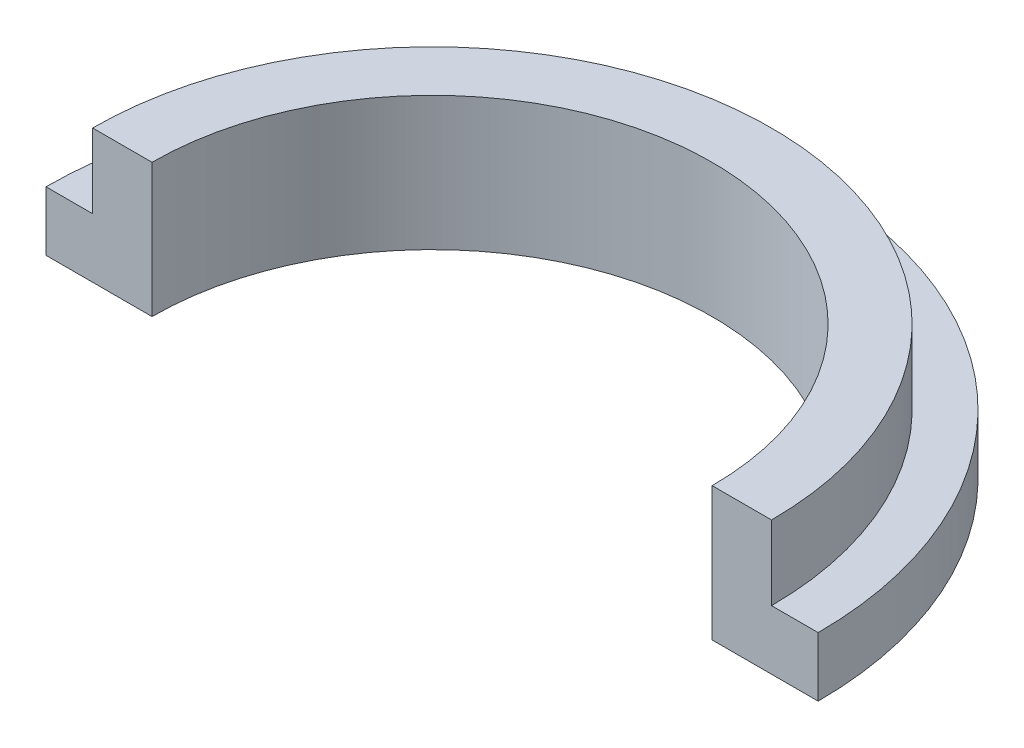
from build123d import *

# Parameters (mm, degrees)
BOSS_EXTRUDE1_DEPTH = 4.5
CUT_EXTRUDE1_DEPTH  = 2.5


with BuildPart() as part:
    # Sketch1 → Boss-Extrude1 (new body)
    with BuildSketch(Plane(origin=(0, 0, 0), x_dir=(1, 0, 0), z_dir=(0, 1, 0))):
        with BuildLine():
            Line((-13, 0), (-9.43, 0))
            ThreePointArc((-9.43, 0), (0, 9.43), (9.43, 0))
            Line((9.43, 0), (13, 0))
            ThreePointArc((13, 0), (0, 13), (-13, 0))
        make_face()
    extrude(amount=BOSS_EXTRUDE1_DEPTH)

    # Sketch2 → Cut-Extrude1 (cut)
    with BuildSketch(Plane(origin=(0, 4.5, 0), x_dir=(1, 0, 0), z_dir=(0, 1, 0))):
        with BuildLine():
            Line((-13, 0), (-11.43, 0))
            ThreePointArc((-11.43, 0), (0, 11.43), (11.43, 0))
            Line((11.43, 0), (13, 0))
            ThreePointArc((13, 0), (0, 13), (-13, 0))
        make_face()
    extrude(amount=-CUT_EXTRUDE1_DEPTH, mode=Mode.SUBTRACT)


solid = part.part
